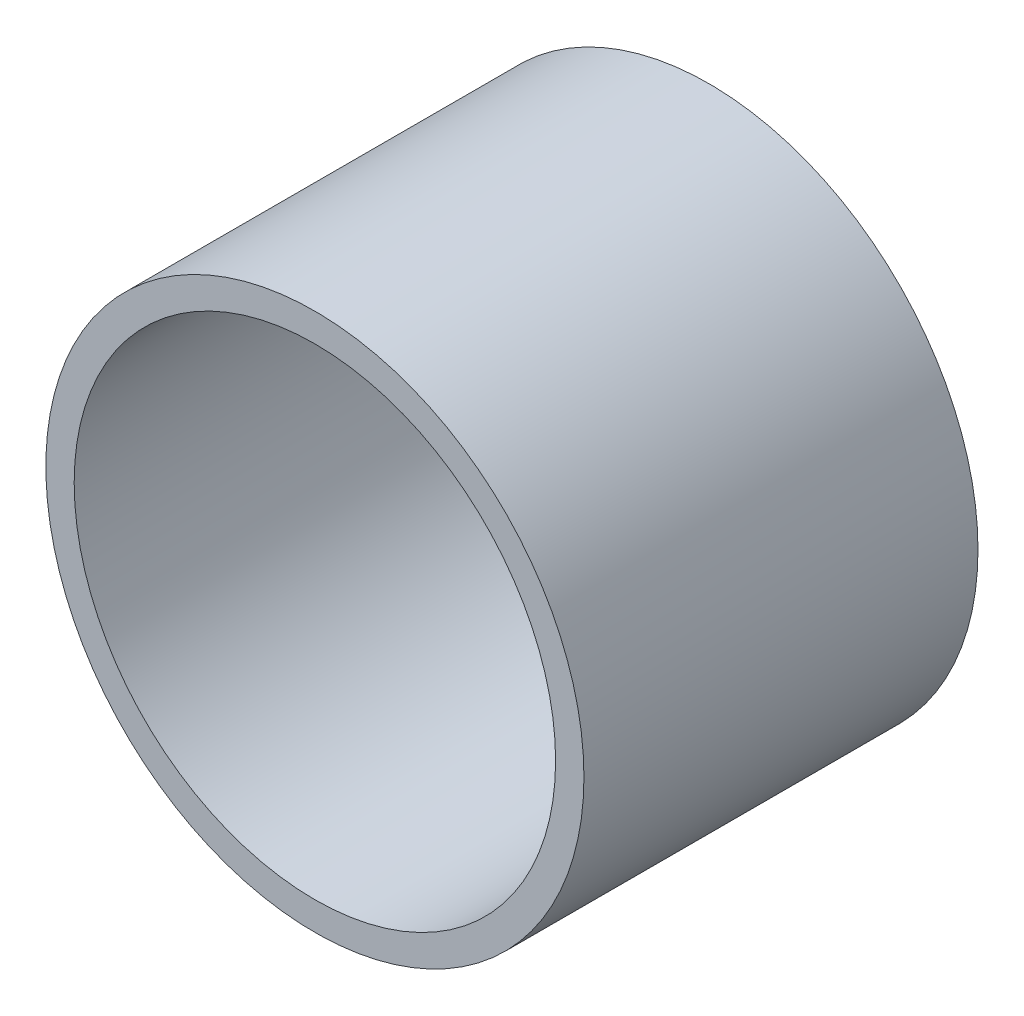
from build123d import *

# Parameters (mm, degrees)
SKETCH1_R           = 57.15
SKETCH1_R_2         = 51.1302
EXTRUDE_THIN1_DEPTH = 41.85


with BuildPart() as part:
    # Sketch1 → Extrude-Thin1 (new body, symmetric)
    with BuildSketch(Plane.XY):
        Circle(SKETCH1_R)
        Circle(SKETCH1_R_2, mode=Mode.SUBTRACT)
    extrude(amount=EXTRUDE_THIN1_DEPTH, both=True)


solid = part.part
